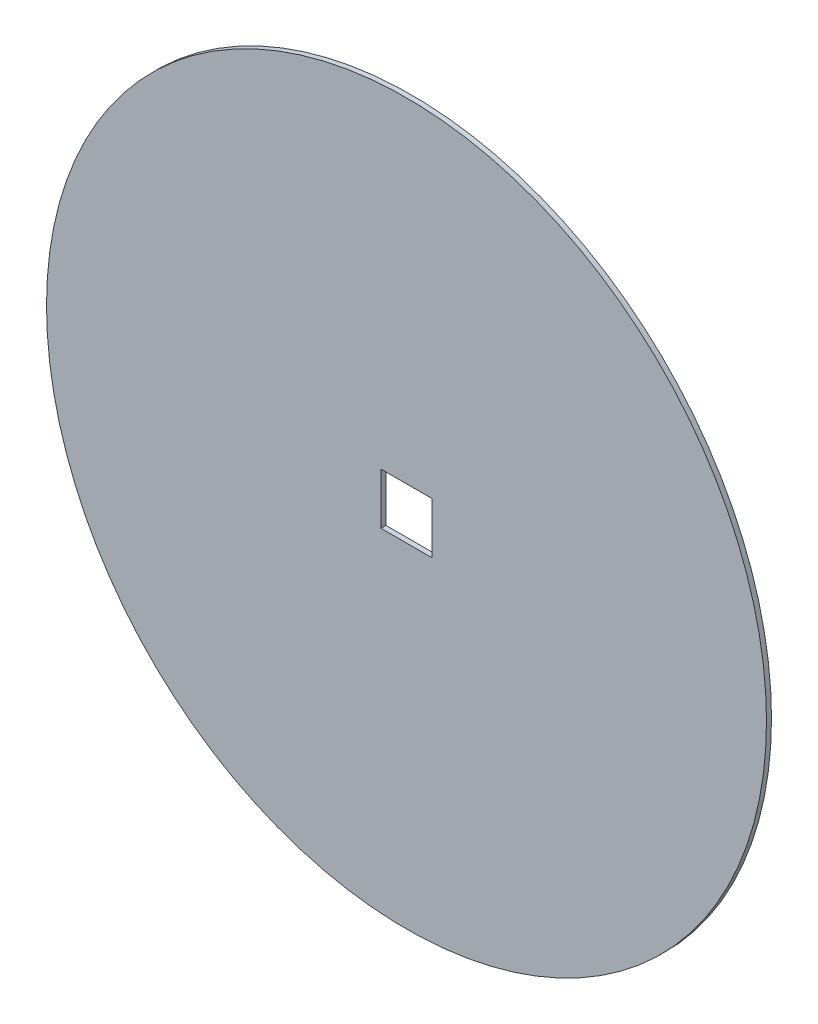
from build123d import *

# Parameters (mm, degrees)
SKETCH1_R           = 144
SKETCH1_W           = 20.5
SKETCH1_H           = 20.5
BOSS_EXTRUDE1_DEPTH = 2


with BuildPart() as part:
    # Sketch1 → Boss-Extrude1 (new body)
    with BuildSketch(Plane.XY):
        Circle(SKETCH1_R)
        Rectangle(SKETCH1_W, SKETCH1_H, mode=Mode.SUBTRACT)
    extrude(amount=BOSS_EXTRUDE1_DEPTH)


solid = part.part
